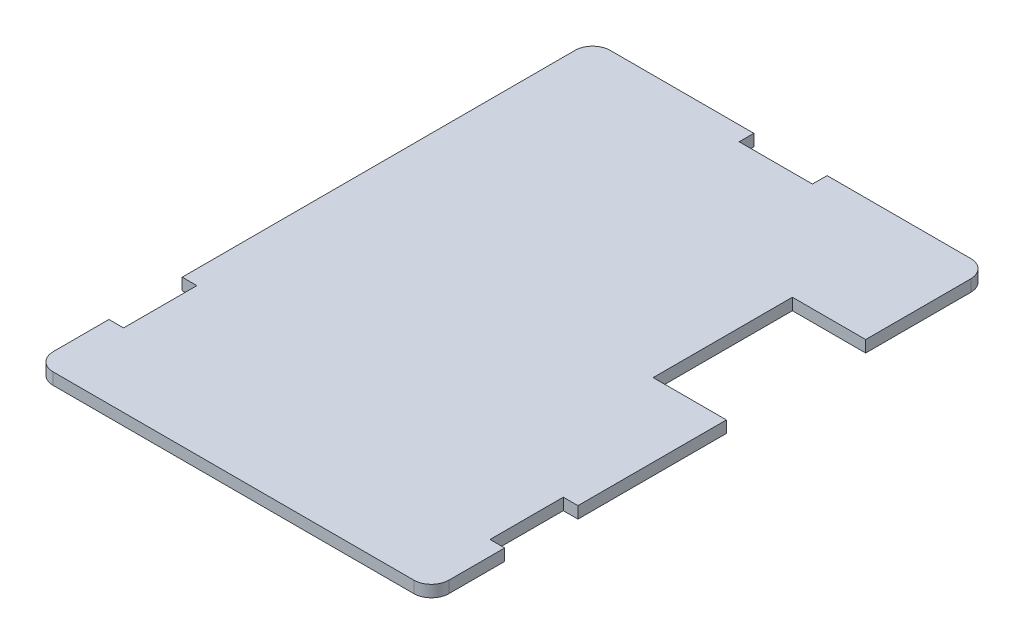
from build123d import *

# Parameters (mm, degrees)
SKETCH_1_W          = 27
SKETCH_1_H          = 38
EXTRUDE_1_DEPTH     = 0.8
FILLET_1_R          = 1.2
CUT_EXTRUDE_1_REACH = 2.8
SKETCH_2_W          = 5
SKETCH_2_H          = 9.5
SKETCH_3_W          = 5
SKETCH_3_H          = 1
SKETCH_3_W_2        = 1
SKETCH_3_H_2        = 5
CUT_EXTRUDE_2_DEPTH = 10


with BuildPart() as part:
    # 草图1 → 凸台-拉伸1 (new body)
    with BuildSketch(Plane(origin=(0, 0, 0), x_dir=(1, 0, 0), z_dir=(0, 1, 0))):
        Rectangle(SKETCH_1_W, SKETCH_1_H)
    extrude(amount=EXTRUDE_1_DEPTH)

    # 圆角1
    fillet_1_edges = [part.edges().sort_by_distance(p)[0] for p in [
        (13.5, 0.4, 19),
        (-13.5, 0.4, 19),
        (-13.5, 0.4, -19),
        (13.5, 0.4, -19),
    ]]
    fillet(fillet_1_edges, radius=FILLET_1_R)

    # 草图2 → 切除-拉伸1 (cut, up to next)
    with BuildSketch(Plane(origin=(0, 0.8, 0), x_dir=(1, 0, 0), z_dir=(0, 1, 0)), mode=Mode.PRIVATE) as cut_extrude_1_sk1:
        with Locations((11, 5.88)):
            Rectangle(SKETCH_2_W, SKETCH_2_H)
    cut_extrude_1_tool1 = extrude(cut_extrude_1_sk1.sketch, amount=-CUT_EXTRUDE_1_REACH, mode=Mode.PRIVATE) & part.part
    add(cut_extrude_1_tool1.solids().sort_by_distance((11, 0.8, -5.88))[0], mode=Mode.SUBTRACT)

    # 草图3 → 切除-拉伸2 (cut)
    with BuildSketch(Plane(origin=(0, 0.8, 0), x_dir=(1, 0, 0), z_dir=(0, 1, 0))):
        with Locations((0, 18.5)):
            Rectangle(SKETCH_3_W, SKETCH_3_H)
        with Locations((-13, -11.5)):
            Rectangle(SKETCH_3_W_2, SKETCH_3_H_2)
        with Locations((13, -11.5)):
            Rectangle(SKETCH_3_W_2, SKETCH_3_H_2)
    extrude(amount=-CUT_EXTRUDE_2_DEPTH, mode=Mode.SUBTRACT)


solid = part.part
